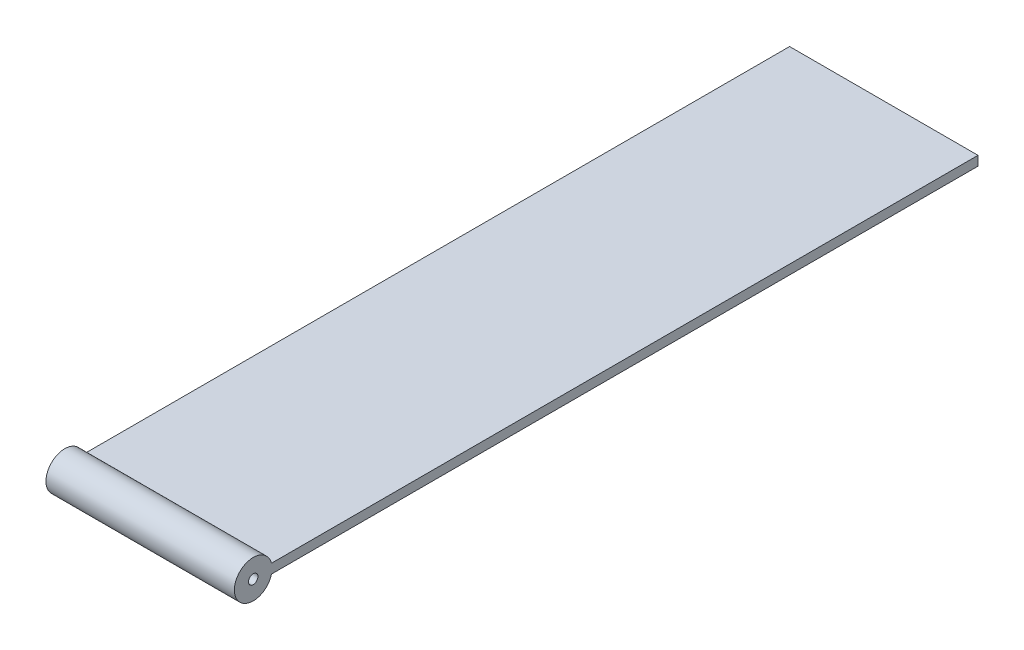
from build123d import *

# Parameters (mm, degrees)
SKETCH1_R                = 4
SKETCH1_R_2              = 1
BOSS_EXTRUDE1_DEPTH      = 20
BOSS_EXTRUDE1_DEPTH_BACK = 20


with BuildPart() as part:
    # Sketch1 → Boss-Extrude1 (new body, two sides)
    with BuildSketch(Plane(origin=(0, 0, 0), x_dir=(0, 0, -1), z_dir=(1, 0, 0))) as boss_extrude1_sk:
        with Locations((-22.845337752, 0)):
            Circle(SKETCH1_R)
        with Locations((-22.845337752, 0)):
            Circle(SKETCH1_R_2, mode=Mode.SUBTRACT)
        with BuildLine():
            Line((131.027645594, 1), (-18.972354406, 1))
            ThreePointArc((-18.972354406, 1), (-18.877218967, 0.50401717), (-18.845337752, 0))
            ThreePointArc((-18.845337752, 0), (-18.877218967, -0.50401717), (-18.972354406, -1))
            Line((-18.972354406, -1), (131.027645594, -1))
            Line((131.027645594, -1), (131.027645594, 1))
        make_face()
    extrude(amount=BOSS_EXTRUDE1_DEPTH)
    extrude(boss_extrude1_sk.sketch, amount=-BOSS_EXTRUDE1_DEPTH_BACK)


solid = part.part
